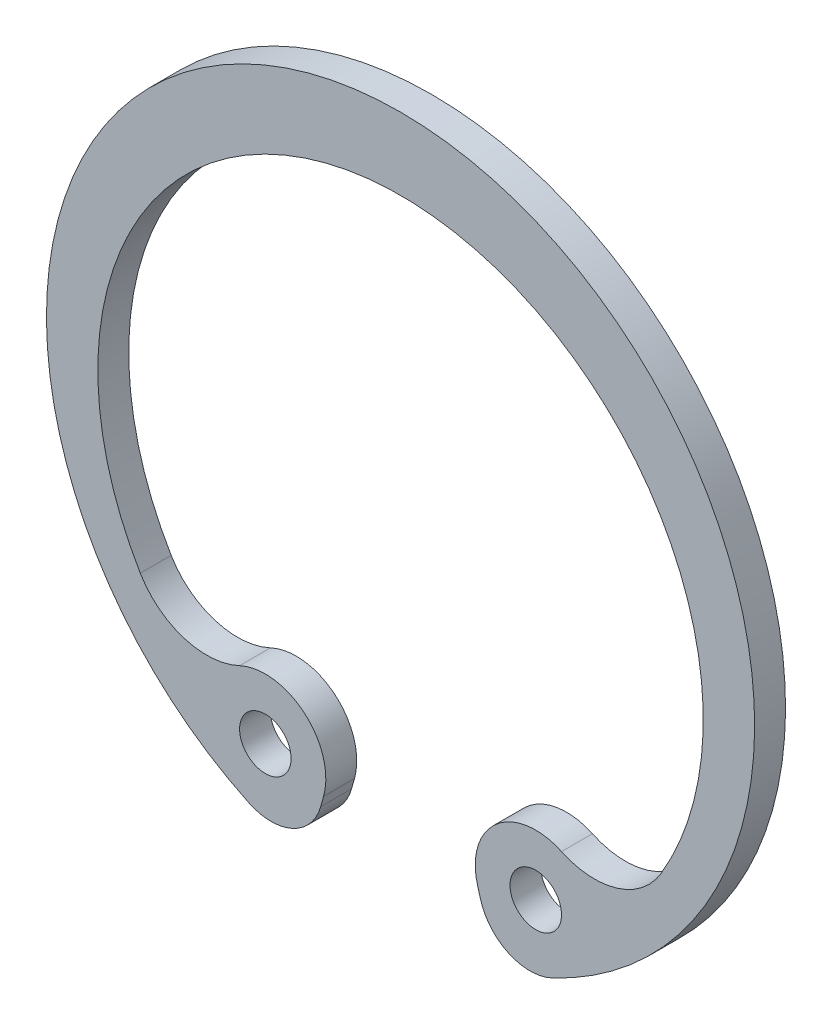
from build123d import *

# Parameters (mm, degrees)
SKETCH_3_R      = 1
EXTRUDE_1_DEPTH = 1.2


with BuildPart() as part:
    # Эскиз3 → Бобышка-Вытянуть1 (new body)
    with BuildSketch(Plane.XY):
        with BuildLine():
            Line((-3.103323876, -11.162371952), (-2.988924759, -10.756549904))
            ThreePointArc((-2.988924759, -10.756549904), (-3.731423363, -8.326162611), (-6.250671205, -7.992281071))
            ThreePointArc((-6.250671205, -7.992281071), (-8.40683178, -8.145513083), (-10.106282686, -6.809708047))
            ThreePointArc((-10.106282686, -6.809708047), (0, 10.95), (10.106282686, -6.809708047))
            ThreePointArc((10.106282686, -6.809708047), (8.40683178, -8.145513083), (6.250671205, -7.992281071))
            ThreePointArc((6.250671205, -7.992281071), (3.731423363, -8.326162611), (2.988924759, -10.756549904))
            Line((2.988924759, -10.756549904), (3.103323876, -11.162371952))
            ThreePointArc((3.103323876, -11.162371952), (4.200183047, -12.44023038), (5.884183094, -12.427344419))
            ThreePointArc((5.884183094, -12.427344419), (0, 13.75), (-5.884183094, -12.427344419))
            ThreePointArc((-5.884183094, -12.427344419), (-4.200183047, -12.44023038), (-3.103323876, -11.162371952))
        make_face()
        with Locations((-5.250773956, -10.118946417)):
            Circle(SKETCH_3_R, mode=Mode.SUBTRACT)
        with Locations((5.250773956, -10.118946417)):
            Circle(SKETCH_3_R, mode=Mode.SUBTRACT)
    extrude(amount=EXTRUDE_1_DEPTH)


solid = part.part
